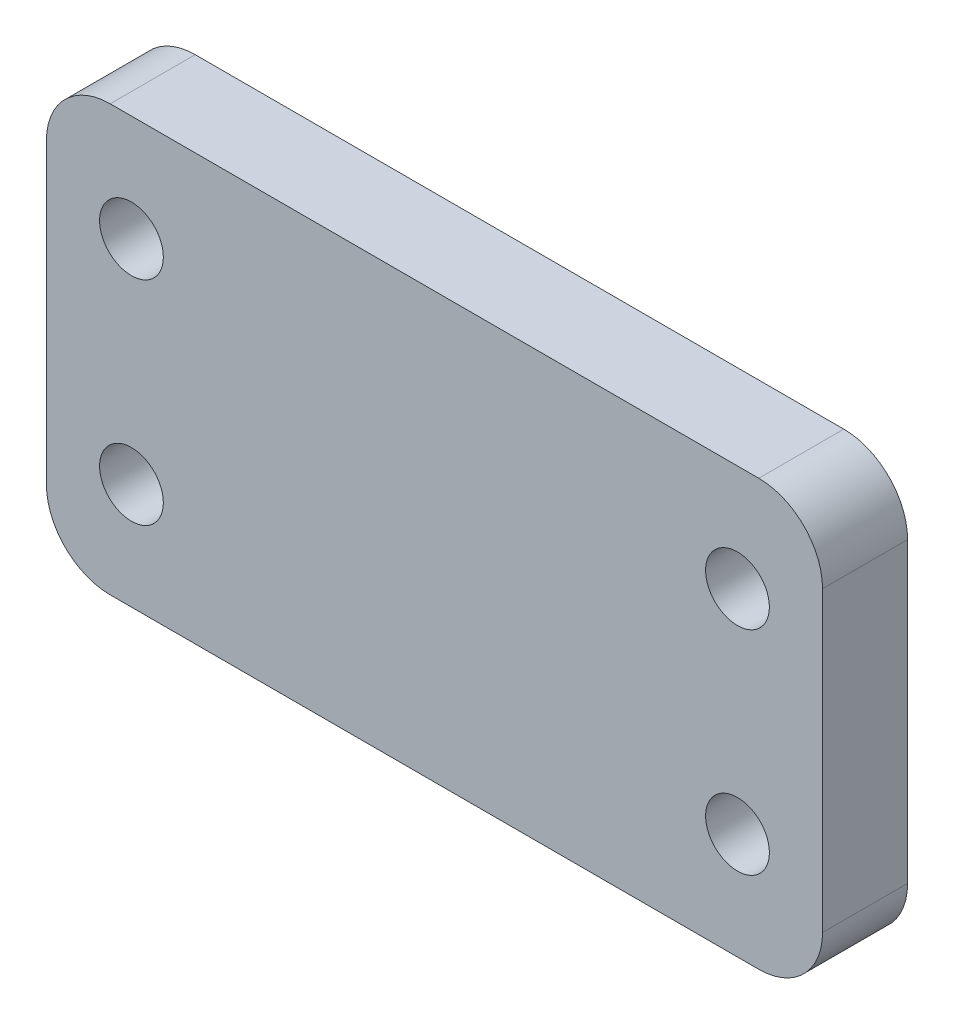
from build123d import *

# Parameters (mm, degrees)
SKETCH1_R           = 1.5
BOSS_EXTRUDE1_DEPTH = 4


with BuildPart() as part:
    # Sketch1 → Boss-Extrude1 (new body)
    with BuildSketch(Plane.XY):
        with BuildLine():
            Line((4.133823449, 1.049127926), (34.633823449, 1.049127926))
            ThreePointArc((34.633823449, 1.049127926), (36.755143792, 1.927807582), (37.633823449, 4.049127926))
            Line((37.633823449, 4.049127926), (37.633823449, 18.049127864))
            ThreePointArc((37.633823449, 18.049127864), (36.755143792, 20.170448208), (34.633823449, 21.049127864))
            Line((34.633823449, 21.049127864), (4.133823449, 21.049127864))
            ThreePointArc((4.133823449, 21.049127864), (2.012503105, 20.170448208), (1.133823449, 18.049127864))
            Line((1.133823449, 18.049127864), (1.133823449, 4.049127926))
            ThreePointArc((1.133823449, 4.049127926), (2.012503105, 1.927807582), (4.133823449, 1.049127926))
        make_face()
        with Locations((33.633823449, 16.049127926)):
            Circle(SKETCH1_R, mode=Mode.SUBTRACT)
        with Locations((33.633823449, 6.049127926)):
            Circle(SKETCH1_R, mode=Mode.SUBTRACT)
        with Locations((5.133823449, 16.049127926)):
            Circle(SKETCH1_R, mode=Mode.SUBTRACT)
        with Locations((5.133823449, 6.049127926)):
            Circle(SKETCH1_R, mode=Mode.SUBTRACT)
    extrude(amount=BOSS_EXTRUDE1_DEPTH)


solid = part.part
